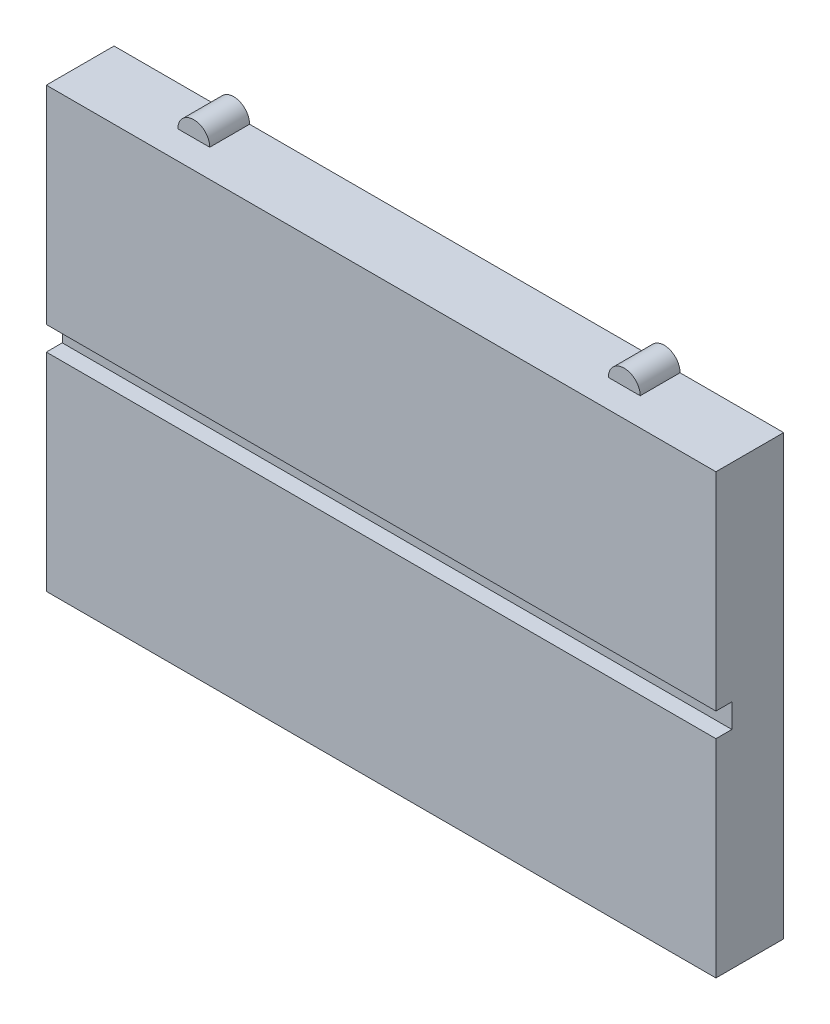
from build123d import *

# Parameters (mm, degrees)
EXTRUDE_2_DEPTH     = 8.5
EXTRUDE_3_DEPTH     = 5
SKETCH_2_W          = 84
SKETCH_2_H          = 3
CUT_EXTRUDE_1_DEPTH = 2


with BuildPart() as part:
    # ｽｹｯﾁ1 → ﾎﾞｽ - 押し出し2 (new body)
    with BuildSketch(Plane.XY):
        Polygon((-42, -27.5), (42, -27.5), (42, 27.5), (29, 27.5), (25, 27.5), (-25, 27.5), (-29, 27.5), (-42, 27.5), (-42, 24.5), (-42, 20.5), (-42, 2), (-42, -2), (-42, -20.5), (-42, -24.5), align=None)
    extrude(amount=EXTRUDE_2_DEPTH)

    # ｽｹｯﾁ1<3> → ﾎﾞｽ - 押し出し3 (add)
    with BuildSketch(Plane.XY):
        with BuildLine():
            ThreePointArc((-42, -20.5), (-44, -22.5), (-42, -24.5))
            Line((-42, -24.5), (-42, -20.5))
        make_face()
        with BuildLine():
            Line((25, 27.5), (29, 27.5))
            ThreePointArc((29, 27.5), (27, 29.5), (25, 27.5))
        make_face()
        with BuildLine():
            ThreePointArc((-42, 2), (-44, 0), (-42, -2))
            Line((-42, -2), (-42, 2))
        make_face()
        with BuildLine():
            Line((-29, 27.5), (-25, 27.5))
            ThreePointArc((-25, 27.5), (-27, 29.5), (-29, 27.5))
        make_face()
        with BuildLine():
            ThreePointArc((-42, 24.5), (-44, 22.5), (-42, 20.5))
            Line((-42, 20.5), (-42, 24.5))
        make_face()
    extrude(amount=EXTRUDE_3_DEPTH)

    # ｽｹｯﾁ2 → ｶｯﾄ - 押し出し1 (cut)
    with BuildSketch(Plane.XY.offset(8.5)):
        Rectangle(SKETCH_2_W, SKETCH_2_H)
    extrude(amount=-CUT_EXTRUDE_1_DEPTH, mode=Mode.SUBTRACT)


solid = part.part
